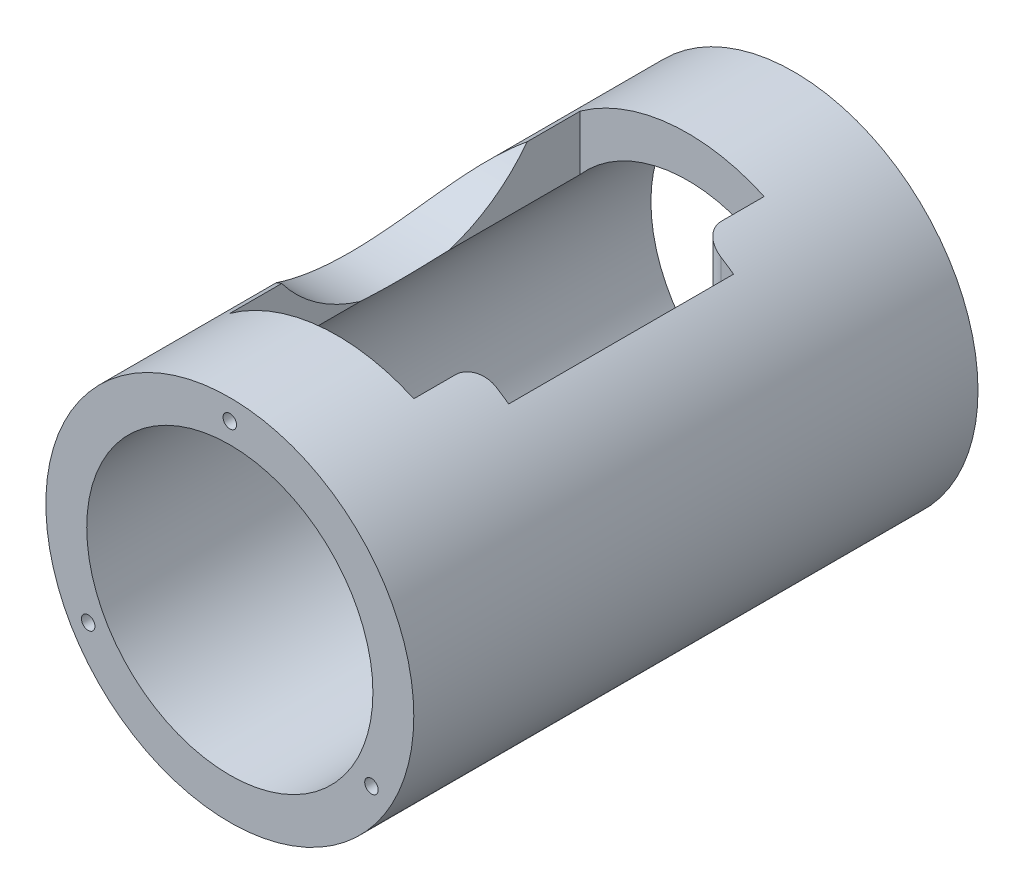
from build123d import *

# Parameters (mm, degrees)
CROQUIS1_R                     = 45
CROQUIS1_R_2                   = 35
SALIENTE_EXTRUIR1_DEPTH        = 69
CORTAR_EXTRUIR1_DEPTH          = 138
CROQUIS3_R                     = 37.5
CORTAR_EXTRUIR2_DEPTH          = 138
TALADRO_ROSCADO_M41_AT_2_COUNT = 2
TALADRO_ROSCADO_M41_AT_2_PITCH = 69.282032303
TALADRO_ROSCADO_M41_AT_3_COUNT = 2
TALADRO_ROSCADO_M41_AT_3_PITCH = 69.282032303


with BuildPart() as part:
    # Croquis1 → Saliente-Extruir1 (new body, symmetric)
    with BuildSketch(Plane.XY):
        Circle(CROQUIS1_R)
        Circle(CROQUIS1_R_2, mode=Mode.SUBTRACT)
    extrude(amount=SALIENTE_EXTRUIR1_DEPTH, both=True)

    # Croquis2 → Cortar-Extruir1 (cut)
    with BuildSketch(Plane(origin=(0, 0, 0), x_dir=(1, 0, 0), z_dir=(0, 1, 0))):
        with BuildLine():
            Line((-26.3, 43), (18.7, 43))
            Line((18.7, 43), (18.7, 32.5))
            ThreePointArc((18.7, 32.5), (20.164466094, 28.964466094), (23.7, 27.5))
            Line((23.7, 27.5), (26.7, 27.5))
            Line((26.7, 27.5), (26.7, -27.5))
            Line((26.7, -27.5), (23.7, -27.5))
            ThreePointArc((23.7, -27.5), (20.164466094, -28.964466094), (18.7, -32.5))
            Line((18.7, -32.5), (18.7, -42.7))
            Line((18.7, -42.7), (-26.3, -42.7))
            Line((-26.3, -42.7), (-26.3, 43))
        make_face()
    extrude(amount=CORTAR_EXTRUIR1_DEPTH, mode=Mode.SUBTRACT)

    # Croquis3 → Cortar-Extruir2 (cut)
    with BuildSketch(Plane(origin=(0, 0, 0), x_dir=(0, 0, -1), z_dir=(1, 0, 0))):
        with Locations((0, 59)):
            Circle(CROQUIS3_R)
    extrude(amount=-CORTAR_EXTRUIR2_DEPTH, mode=Mode.SUBTRACT)

    # Croquis5 → Taladro roscado M41 (revolve, cut)
    with BuildSketch(Plane(origin=(0, 40, 69), x_dir=(0, -1, 0), z_dir=(1, 0, 0))):
        Polygon((0, 0), (0, 15.991420021), (1.65, 15), (1.65, 0), align=None)
    taladro_roscado_m41 = revolve(axis=Axis((0, 40, 75.35), (0, 0, -1)), mode=Mode.SUBTRACT)

    # Taladro roscado M41 at 2: Taladro roscado M41 ×2
    with Locations(*[Vector(0.5, -0.866025404, 0) * (i * TALADRO_ROSCADO_M41_AT_2_PITCH) for i in range(1, TALADRO_ROSCADO_M41_AT_2_COUNT)]):
        add(taladro_roscado_m41, mode=Mode.SUBTRACT)

    # Taladro roscado M41 at 3: Taladro roscado M41 ×2
    with Locations(*[Vector(-0.5, -0.866025404, 0) * (i * TALADRO_ROSCADO_M41_AT_3_PITCH) for i in range(1, TALADRO_ROSCADO_M41_AT_3_COUNT)]):
        add(taladro_roscado_m41, mode=Mode.SUBTRACT)

    # Simetría1: Taladro roscado M41 across plane
    add(taladro_roscado_m41.mirror(Plane.XY), mode=Mode.SUBTRACT)

    # Simetría1 copy 1 sketch → Simetría1 copy 1 (revolve, cut)
    with BuildSketch(Plane(origin=(34.641016151, -20, -69), x_dir=(0, -1, 0), z_dir=(1, 0, 0))):
        Polygon((0, 0), (0, -15.991420021), (1.65, -15), (1.65, 0), align=None)
    revolve(axis=Axis((34.641016151, -20, -75.35), (0, 0, -1)), mode=Mode.SUBTRACT)

    # Simetría1 copy 2 sketch → Simetría1 copy 2 (revolve, cut)
    with BuildSketch(Plane(origin=(-34.641016151, -20, -69), x_dir=(0, -1, 0), z_dir=(1, 0, 0))):
        Polygon((0, 0), (0, -15.991420021), (1.65, -15), (1.65, 0), align=None)
    revolve(axis=Axis((-34.641016151, -20, -75.35), (0, 0, -1)), mode=Mode.SUBTRACT)


solid = part.part
